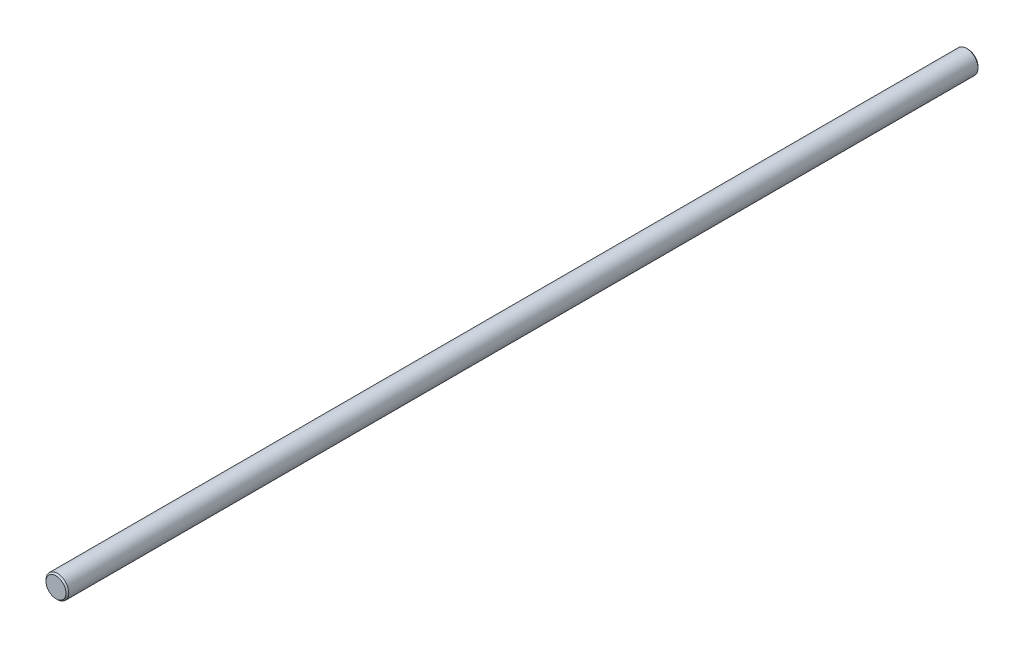
from build123d import *

# Parameters (mm, degrees)
SKETCH1_R           = 4
BOSS_EXTRUDE1_DEPTH = 320
CHAMFER1_SIZE       = 0.5


with BuildPart() as part:
    # Sketch1 → Boss-Extrude1 (new body)
    with BuildSketch(Plane.XY):
        Circle(SKETCH1_R)
    extrude(amount=-BOSS_EXTRUDE1_DEPTH)

    # Chamfer1
    chamfer1_edges = [part.edges().sort_by_distance(p)[0] for p in [
        (-4, 0, 0),
        (-4, 0, -320),
    ]]
    chamfer(chamfer1_edges, length=CHAMFER1_SIZE)


solid = part.part
